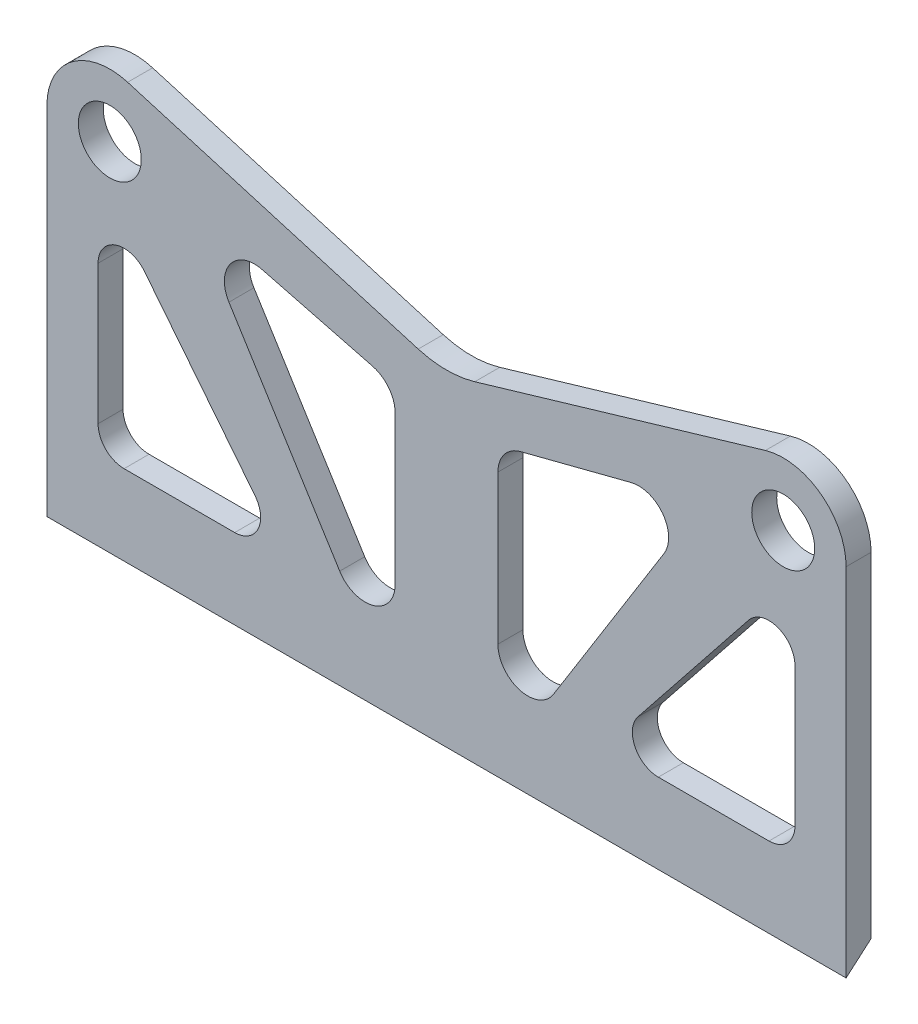
from build123d import *

# Parameters (mm, degrees)
BOSS_EXTRUDE1_DEPTH = 3.175
SKETCH1_8_R         = 3.999992
CUT_EXTRUDE1_DEPTH  = 20.701
SKETCH1_9_R         = 3.999992
CUT_EXTRUDE2_DEPTH  = 19.431
CUT_EXTRUDE8_DEPTH  = 20.193
FILLET1_R           = 12.7
CUT_EXTRUDE9_DEPTH  = 126.238


with BuildPart() as part:
    # Sketch1 → Boss-Extrude1 (new body)
    with BuildSketch(Plane.XY.offset(1577.629912845)):
        with BuildLine():
            Line((50.788624607, 668.00159627), (50.788624607, 617.20159627))
            Line((50.788624607, 617.20159627), (-50.788624607, 617.20159627))
            Line((-50.788624607, 617.20159627), (-50.788624607, 668.00159627))
            ThreePointArc((-50.788624607, 668.00159627), (-47.580641699, 674.404695353), (-40.531332209, 675.668842459))
            Line((-40.531332209, 675.668842459), (0, 663.705728602))
            Line((0, 663.705728602), (40.531332209, 675.668842459))
            ThreePointArc((40.531332209, 675.668842459), (47.580641699, 674.404695353), (50.788624607, 668.00159627))
        make_face()
    extrude(amount=BOSS_EXTRUDE1_DEPTH)

    # Sketch1_8 → Cut-Extrude1 (cut)
    with BuildSketch(Plane.XY.offset(1577.629912845)):
        with Locations((42.794374999, 668.00159627)):
            Circle(SKETCH1_8_R)
    extrude(amount=CUT_EXTRUDE1_DEPTH, mode=Mode.SUBTRACT)

    # Sketch1_9 → Cut-Extrude2 (cut)
    with BuildSketch(Plane.XY.offset(1577.629912845)):
        with Locations((-42.794374999, 668.00159627)):
            Circle(SKETCH1_9_R)
    extrude(amount=CUT_EXTRUDE2_DEPTH, mode=Mode.SUBTRACT)

    # Sketch1_17 → Cut-Extrude8 (cut)
    with BuildSketch(Plane.XY.offset(1577.629912845)):
        with BuildLine():
            Line((13.57510941, 635.333202119), (27.654813941, 657.899286932))
            ThreePointArc((27.654813941, 657.899286932), (27.495220576, 662.168612345), (23.471836113, 663.605618605))
            Line((23.471836113, 663.605618605), (9.392131582, 659.978176021))
            ThreePointArc((9.392131582, 659.978176021), (7.331231426, 658.6225908), (6.532685397, 656.288657429))
            Line((6.532685397, 656.288657429), (6.532685397, 637.350015199))
            ThreePointArc((6.532685397, 637.350015199), (9.293741997, 633.687254253), (13.57510941, 635.333202119))
        make_face()
        with BuildLine():
            Line((38.399954792, 655.927224031), (24.340132355, 638.265442375))
            ThreePointArc((24.340132355, 638.265442375), (23.94914071, 634.774942338), (26.92351994, 632.906913117))
            Line((26.92351994, 632.906913117), (40.983342377, 632.906913117))
            ThreePointArc((40.983342377, 632.906913117), (43.318208968, 633.874046526), (44.285342377, 636.208913117))
            Line((44.285342377, 636.208913117), (44.285342377, 653.870694774))
            ThreePointArc((44.285342377, 653.870694774), (42.072575638, 656.987868959), (38.399954792, 655.927224031))
        make_face()
        with BuildLine():
            Line((-44.285342377, 636.208913117), (-44.285342377, 653.870694774))
            ThreePointArc((-44.285342377, 653.870694774), (-42.072575638, 656.987868959), (-38.399954792, 655.927224031))
            Line((-38.399954792, 655.927224031), (-24.340132355, 638.265442375))
            ThreePointArc((-24.340132355, 638.265442375), (-23.94914071, 634.774942338), (-26.92351994, 632.906913117))
            Line((-26.92351994, 632.906913117), (-40.983342377, 632.906913117))
            ThreePointArc((-40.983342377, 632.906913117), (-43.318208968, 633.874046526), (-44.285342377, 636.208913117))
        make_face()
        with BuildLine():
            Line((-6.532685397, 656.288657429), (-6.532685397, 637.350015199))
            ThreePointArc((-6.532685397, 637.350015199), (-9.293741997, 633.687254253), (-13.57510941, 635.333202119))
            Line((-13.57510941, 635.333202119), (-27.654813941, 657.899286932))
            ThreePointArc((-27.654813941, 657.899286932), (-27.495220576, 662.168612345), (-23.471836113, 663.605618605))
            Line((-23.471836113, 663.605618605), (-9.392131582, 659.978176021))
            ThreePointArc((-9.392131582, 659.978176021), (-7.331231426, 658.6225908), (-6.532685397, 656.288657429))
        make_face()
    extrude(amount=CUT_EXTRUDE8_DEPTH, mode=Mode.SUBTRACT)

    # Fillet1
    fillet1_edges = [part.edges().sort_by_distance(p)[0] for p in [
        (0, 663.705728602, 1579.217412845),
    ]]
    fillet(fillet1_edges, radius=FILLET1_R)

    # Sketch5 → Cut-Extrude9 (cut)
    with BuildSketch(Plane(origin=(50.788624607, 0, 0), x_dir=(0, 0, -1), z_dir=(1, 0, 0))):
        Polygon((-1577.636028368, 625.473682851), (-1580.804912845, 622.730103166), (-1584.510921517, 619.521488216), (-1584.510921517, 612.304065089), (-1576.030251426, 612.304065089), (-1576.030251426, 626.863944008), align=None)
    extrude(amount=-CUT_EXTRUDE9_DEPTH, mode=Mode.SUBTRACT)


solid = part.part
